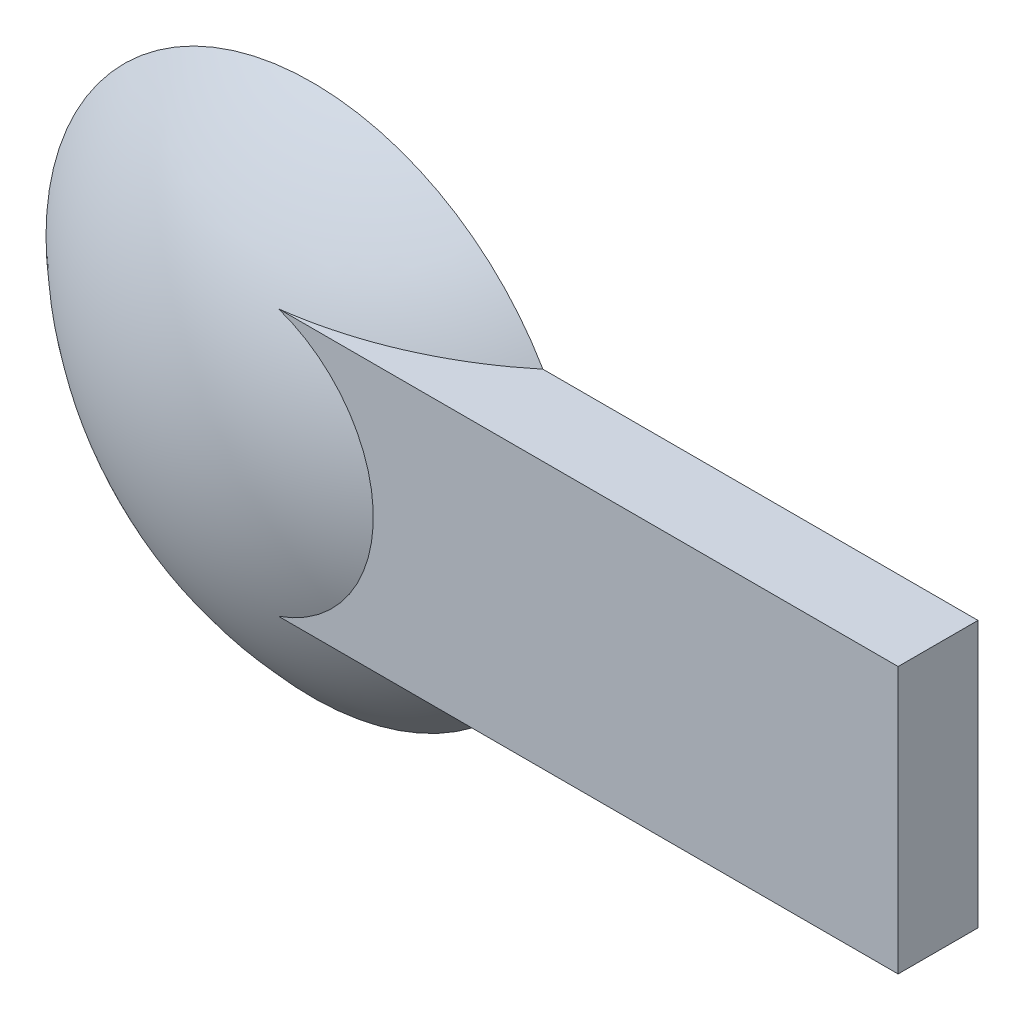
from build123d import *

# Parameters (mm, degrees)
BOSS_EXTRU_1_REACH = 37
ESQUISSE2_W        = 3
ESQUISSE2_H        = 10


with BuildPart() as part:
    # Esquisse1 → Révolution1 (revolve)
    with BuildSketch(Plane(origin=(0, 0, 0), x_dir=(1, 0, 0), z_dir=(0, 1, 0))):
        with BuildLine():
            Line((0, 0), (0, -4))
            ThreePointArc((0, -4), (-5.385164807, -2.962912018), (-10, 0))
            Line((-10, 0), (0, 0))
        make_face()
    revolve(axis=Axis((0, 0, 0), (0, 0, 1)))

    # Esquisse2 → Boss.-Extru.1 (add, up to next)
    with BuildSketch(Plane(origin=(25, 0, -10), x_dir=(0, 0, 1), z_dir=(-1, 0, 0)), mode=Mode.PRIVATE) as boss_extru_1_sk1:
        with Locations((11.5, 0)):
            Rectangle(ESQUISSE2_W, ESQUISSE2_H)
    boss_extru_1_tool1 = extrude(boss_extru_1_sk1.sketch, amount=BOSS_EXTRU_1_REACH, mode=Mode.PRIVATE) - part.part
    add(boss_extru_1_tool1.solids().sort_by_distance((25, 0, 1.5))[0])


solid = part.part
